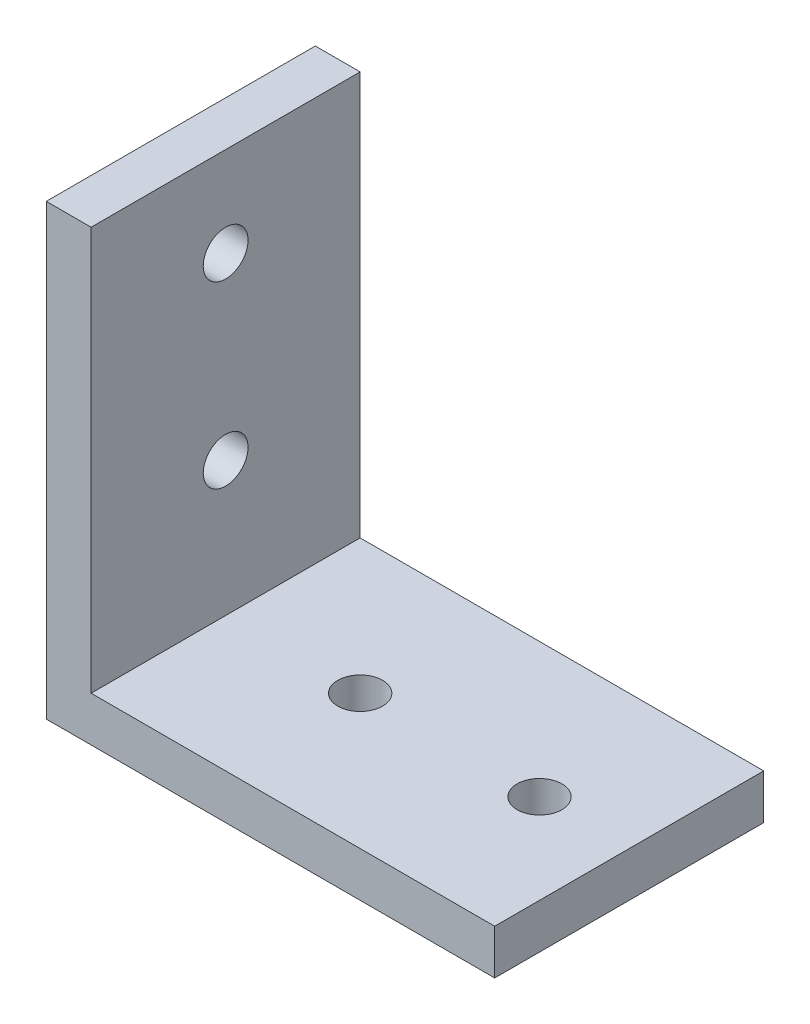
from build123d import *

# Parameters (mm, degrees)
BOSS_EXTRUDE1_DEPTH = 30
SKETCH2_R           = 5
CUT_EXTRUDE1_DEPTH  = 11
SKETCH3_R           = 5
CUT_EXTRUDE2_DEPTH  = 11


with BuildPart() as part:
    # Sketch1 → Boss-Extrude1 (new body, symmetric)
    with BuildSketch(Plane.XY):
        Polygon((0, 0), (0, 100), (10, 100), (10, 10), (100, 10), (100, 0), align=None)
    extrude(amount=BOSS_EXTRUDE1_DEPTH, both=True)

    # Sketch2 → Cut-Extrude1 (cut, through all)
    with BuildSketch(Plane(origin=(10, 0, 0), x_dir=(0, 0, -1), z_dir=(1, 0, 0))):
        with Locations((0, 40)):
            Circle(SKETCH2_R)
        with Locations((0, 80)):
            Circle(SKETCH2_R)
    extrude(amount=-CUT_EXTRUDE1_DEPTH, mode=Mode.SUBTRACT)

    # Sketch3 → Cut-Extrude2 (cut, through all)
    with BuildSketch(Plane(origin=(0, 10, 0), x_dir=(0, 0, -1), z_dir=(0, 1, 0))):
        with Locations((0, -80)):
            Circle(SKETCH3_R)
        with Locations((0, -40)):
            Circle(SKETCH3_R)
    extrude(amount=-CUT_EXTRUDE2_DEPTH, mode=Mode.SUBTRACT)


solid = part.part
